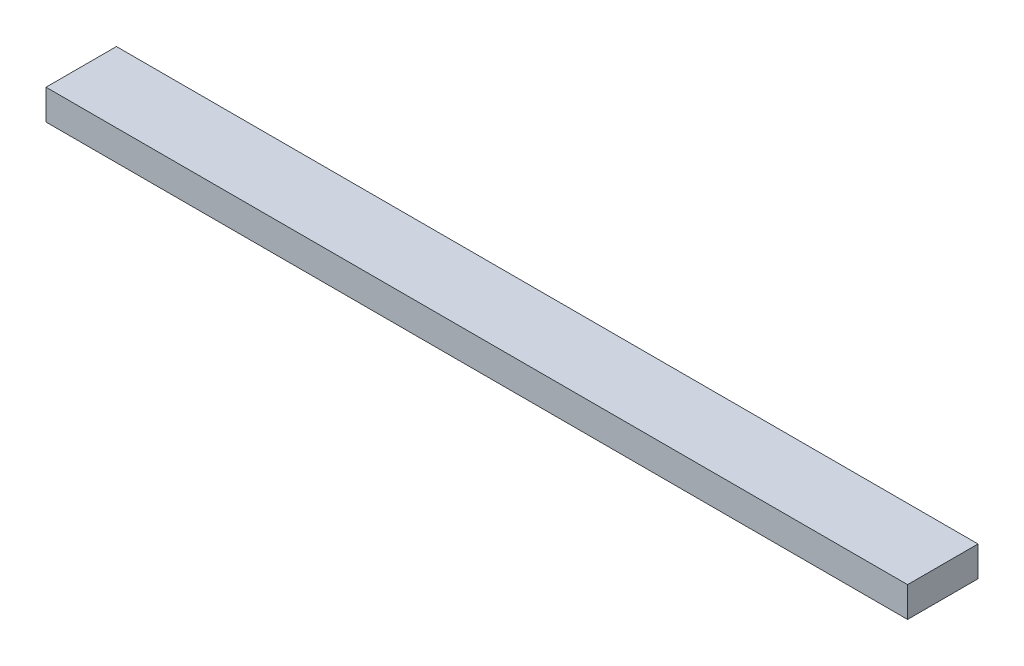
from build123d import *

# Parameters (mm, degrees)
SKETCH1_W           = 1087.4502
SKETCH1_H           = 88.9
BOSS_EXTRUDE1_DEPTH = 38.1


with BuildPart() as part:
    # Sketch1 → Boss-Extrude1 (new body)
    with BuildSketch(Plane(origin=(0, 0, 0), x_dir=(1, 0, 0), z_dir=(0, 1, 0))):
        with Locations((543.7251, 44.45)):
            Rectangle(SKETCH1_W, SKETCH1_H)
    extrude(amount=BOSS_EXTRUDE1_DEPTH)


solid = part.part
